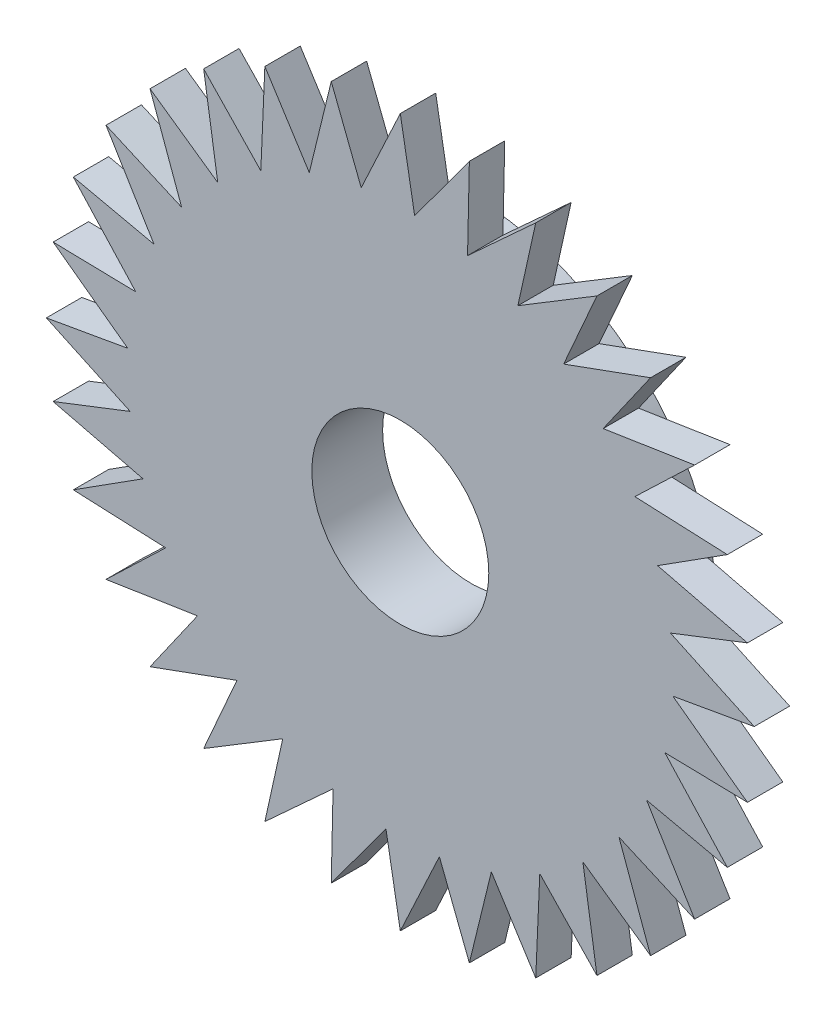
from build123d import *

# Parameters (mm, degrees)
Y_KSEKLIK_EKSTR_ZYON1_DEPTH = 1
IZIM3_R                     = 7
Y_KSEKLIK_EKSTR_ZYON2_DEPTH = 1
IZIM4_R                     = 2.5
KES_EKSTR_ZYON1_DEPTH       = 4


with BuildPart() as part:
    # Çizim1 → Yükseklik-Ekstrüzyon1 (new body)
    with BuildSketch(Plane.XY):
        Polygon((0, 10), (0.405515134, 7.700209394), (1.95090322, 9.807852804), (1.899959604, 7.473139952), (3.826834324, 9.238795325), (3.321389693, 6.958881932), (5.55570233, 8.314696123), (4.615180638, 6.177197982), (7.071067812, 7.071067812), (5.73161278, 5.158127778), (8.314696123, 5.55570233), (6.627782257, 3.940833616), (9.238795325, 3.826834324), (7.269249778, 2.572095429), (9.807852804, 1.95090322), (7.631364108, 1.104513056), (10, 0), (7.700209394, -0.405515134), (9.807852804, -1.95090322), (7.473139952, -1.899959604), (9.238795325, -3.826834324), (6.958881932, -3.321389693), (8.314696123, -5.55570233), (6.177197982, -4.615180638), (7.071067812, -7.071067812), (5.158127778, -5.73161278), (5.55570233, -8.314696123), (3.940833616, -6.627782257), (3.826834324, -9.238795325), (2.572095429, -7.269249778), (1.95090322, -9.807852804), (1.104513056, -7.631364108), (0, -10), (-0.405515134, -7.700209394), (-1.95090322, -9.807852804), (-1.899959604, -7.473139952), (-3.826834324, -9.238795325), (-3.321389693, -6.958881932), (-5.55570233, -8.314696123), (-4.615180638, -6.177197982), (-7.071067812, -7.071067812), (-5.73161278, -5.158127778), (-8.314696123, -5.55570233), (-6.627782257, -3.940833616), (-9.238795325, -3.826834324), (-7.269249778, -2.572095429), (-9.807852804, -1.95090322), (-7.631364108, -1.104513056), (-10, 0), (-7.700209394, 0.405515134), (-9.807852804, 1.95090322), (-7.473139952, 1.899959604), (-9.238795325, 3.826834324), (-6.958881932, 3.321389693), (-8.314696123, 5.55570233), (-6.177197982, 4.615180638), (-7.071067812, 7.071067812), (-5.158127778, 5.73161278), (-5.55570233, 8.314696123), (-3.940833616, 6.627782257), (-3.826834324, 9.238795325), (-2.572095429, 7.269249778), (-1.95090322, 9.807852804), (-1.104513056, 7.631364108), align=None)
    extrude(amount=Y_KSEKLIK_EKSTR_ZYON1_DEPTH)

    # Çizim3 → Yükseklik-Ekstrüzyon2 (add)
    with BuildSketch(Plane(origin=(0, 0, 0), x_dir=(-1, 0, 0), z_dir=(0, 0, -1))):
        Circle(IZIM3_R)
    extrude(amount=Y_KSEKLIK_EKSTR_ZYON2_DEPTH)

    # Çizim4 → Kes-Ekstrüzyon1 (cut)
    with BuildSketch(Plane(origin=(0, 0, -1), x_dir=(-1, 0, 0), z_dir=(0, 0, -1))):
        Circle(IZIM4_R)
    extrude(amount=-KES_EKSTR_ZYON1_DEPTH, mode=Mode.SUBTRACT)


solid = part.part
